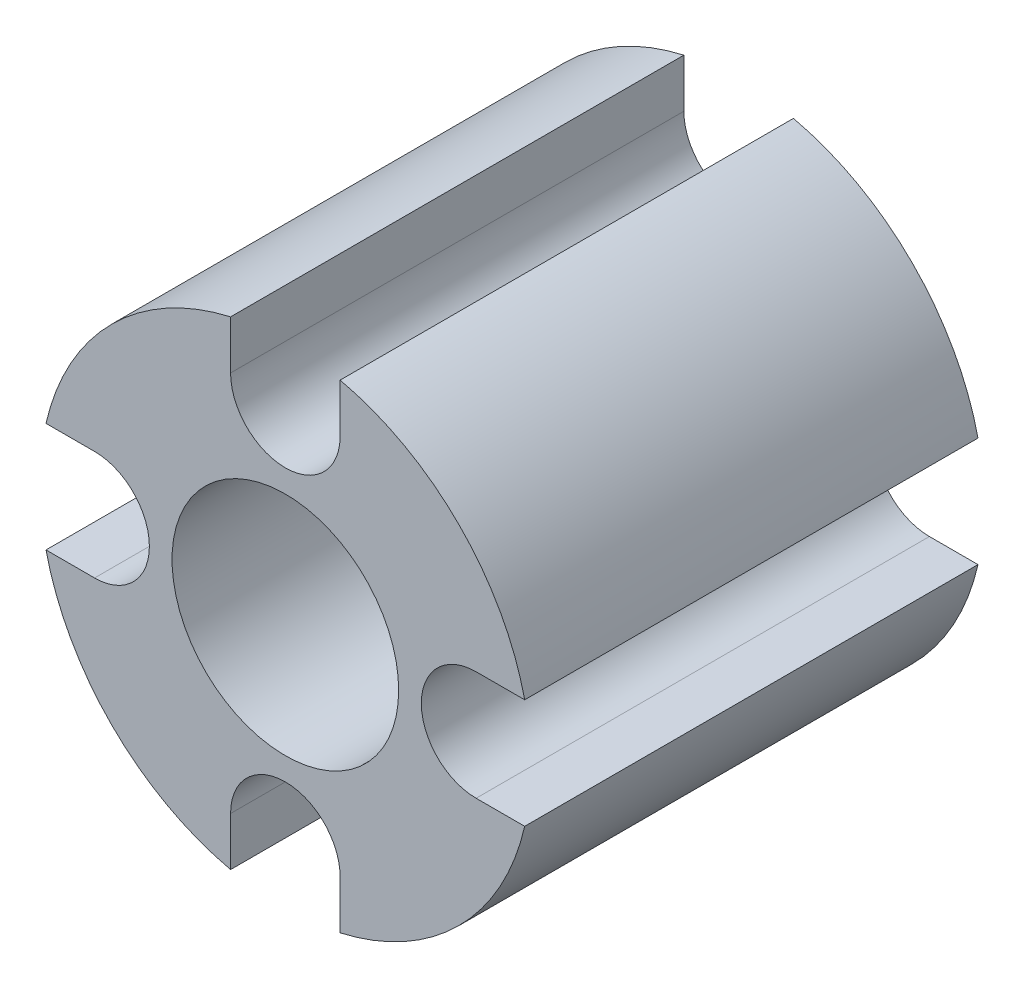
from build123d import *

# Parameters (mm, degrees)
ESQUISSE1_R        = 1.5
BOSS_EXTRU_2_DEPTH = 6


with BuildPart() as part:
    # Esquisse1 → Boss.-Extru.2 (new body)
    with BuildSketch(Plane.XY):
        with BuildLine():
            Line((-0.725, 2.525), (-0.725, 3.168102745))
            ThreePointArc((-0.725, 3.168102745), (-2.298097039, 2.298097039), (-3.168102745, 0.725))
            Line((-3.168102745, 0.725), (-2.525, 0.725))
            ThreePointArc((-2.525, 0.725), (-1.8, 0), (-2.525, -0.725))
            Line((-2.525, -0.725), (-3.168102745, -0.725))
            ThreePointArc((-3.168102745, -0.725), (-2.298097039, -2.298097039), (-0.725, -3.168102745))
            Line((-0.725, -3.168102745), (-0.725, -2.525))
            ThreePointArc((-0.725, -2.525), (0, -1.8), (0.725, -2.525))
            Line((0.725, -2.525), (0.725, -3.168102745))
            ThreePointArc((0.725, -3.168102745), (2.298097039, -2.298097039), (3.168102745, -0.725))
            Line((3.168102745, -0.725), (2.525, -0.725))
            ThreePointArc((2.525, -0.725), (1.8, 0), (2.525, 0.725))
            Line((2.525, 0.725), (3.168102745, 0.725))
            ThreePointArc((3.168102745, 0.725), (2.298097039, 2.298097039), (0.725, 3.168102745))
            Line((0.725, 3.168102745), (0.725, 2.525))
            ThreePointArc((0.725, 2.525), (0, 1.8), (-0.725, 2.525))
        make_face()
        Circle(ESQUISSE1_R, mode=Mode.SUBTRACT)
    extrude(amount=BOSS_EXTRU_2_DEPTH)


solid = part.part
